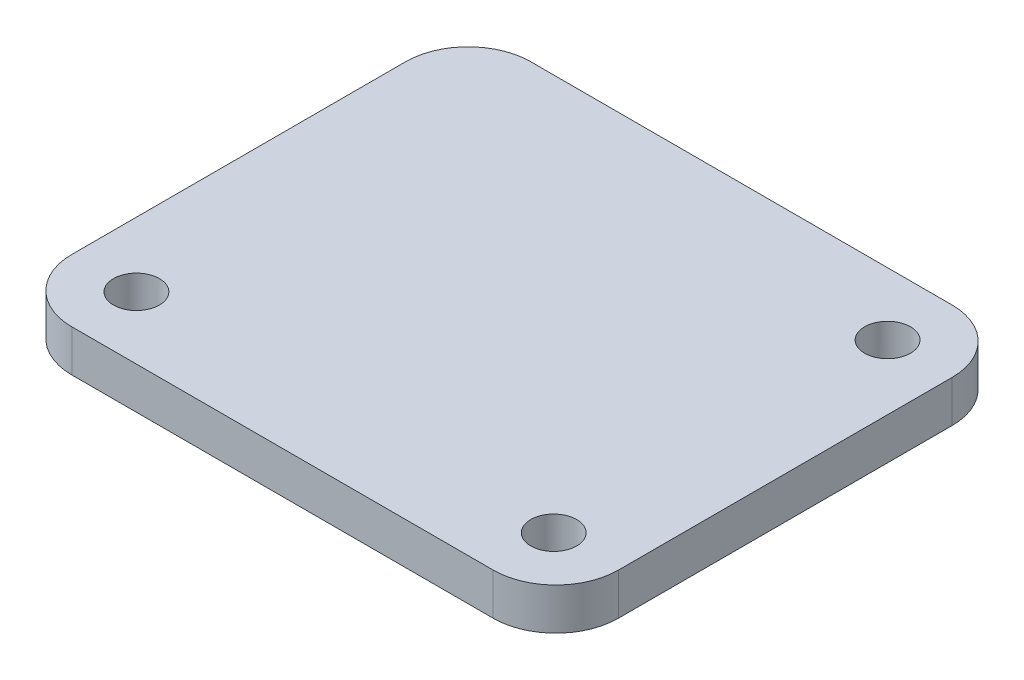
from build123d import *

# Parameters (mm, degrees)
SKETCH1_W           = 33.274
SKETCH1_H           = 27.94
BOSS_EXTRUDE1_DEPTH = 2.54
SKETCH2_R           = 1.397
CUT_EXTRUDE1_DEPTH  = 2.54
FILLET1_R           = 3.81


with BuildPart() as part:
    # Sketch1 → Boss-Extrude1 (new body)
    with BuildSketch(Plane(origin=(0, 0, 0), x_dir=(1, 0, 0), z_dir=(0, 1, 0))):
        Rectangle(SKETCH1_W, SKETCH1_H)
    extrude(amount=BOSS_EXTRUDE1_DEPTH)

    # Sketch2 → Cut-Extrude1 (cut)
    with BuildSketch(Plane(origin=(0, 2.54, 0), x_dir=(1, 0, 0), z_dir=(0, 1, 0))):
        with Locations((12.7, -10.16)):
            Circle(SKETCH2_R)
        with Locations((-12.7, -10.16)):
            Circle(SKETCH2_R)
        with Locations((12.7, 10.16)):
            Circle(SKETCH2_R)
    extrude(amount=-CUT_EXTRUDE1_DEPTH, mode=Mode.SUBTRACT)

    # Fillet1
    fillet1_edges = [part.edges().sort_by_distance(p)[0] for p in [
        (16.637, 1.27, 13.97),
        (-16.637, 1.27, 13.97),
        (-16.637, 1.27, -13.97),
        (16.637, 1.27, -13.97),
    ]]
    fillet(fillet1_edges, radius=FILLET1_R)


solid = part.part
